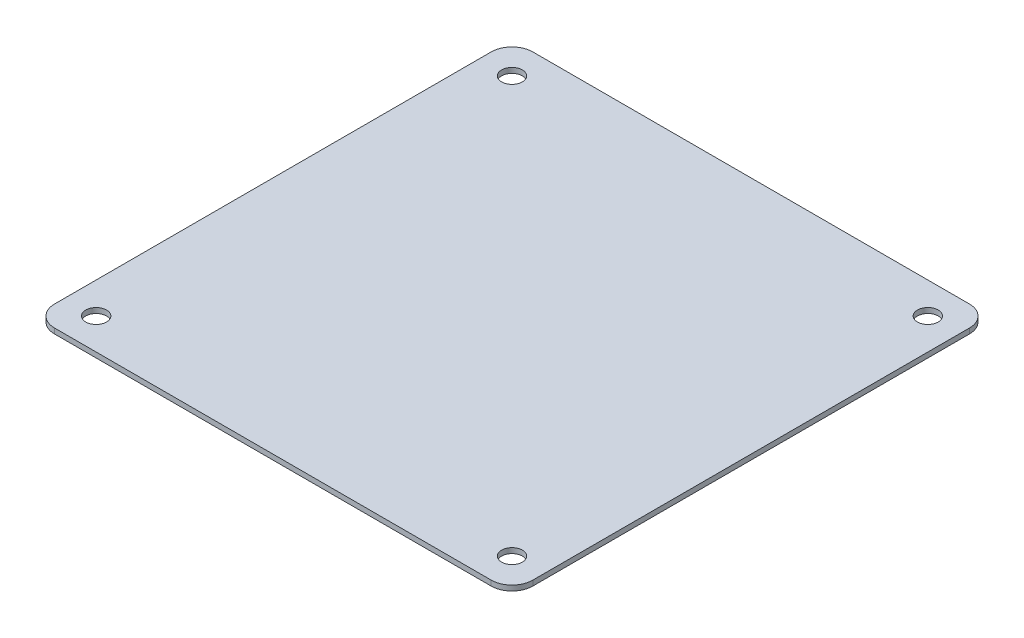
from build123d import *

# Parameters (mm, degrees)
SKETCH1_R           = 1
BOSS_EXTRUDE1_DEPTH = 0.5


with BuildPart() as part:
    # Sketch1 → Boss-Extrude1 (new body)
    with BuildSketch(Plane(origin=(0, 0, 0), x_dir=(1, 0, 0), z_dir=(0, 1, 0))):
        with BuildLine():
            Line((-21, 23), (21, 23))
            ThreePointArc((21, 23), (22.414213562, 22.414213562), (23, 21))
            Line((23, 21), (23, -21))
            ThreePointArc((23, -21), (22.414213562, -22.414213562), (21, -23))
            Line((21, -23), (-21, -23))
            ThreePointArc((-21, -23), (-22.414213562, -22.414213562), (-23, -21))
            Line((-23, -21), (-23, 21))
            ThreePointArc((-23, 21), (-22.414213562, 22.414213562), (-21, 23))
        make_face()
        with Locations((-20, 20)):
            Circle(SKETCH1_R, mode=Mode.SUBTRACT)
        with Locations((20, 20)):
            Circle(SKETCH1_R, mode=Mode.SUBTRACT)
        with Locations((-20, -20)):
            Circle(SKETCH1_R, mode=Mode.SUBTRACT)
        with Locations((20, -20)):
            Circle(SKETCH1_R, mode=Mode.SUBTRACT)
    extrude(amount=BOSS_EXTRUDE1_DEPTH)


solid = part.part
